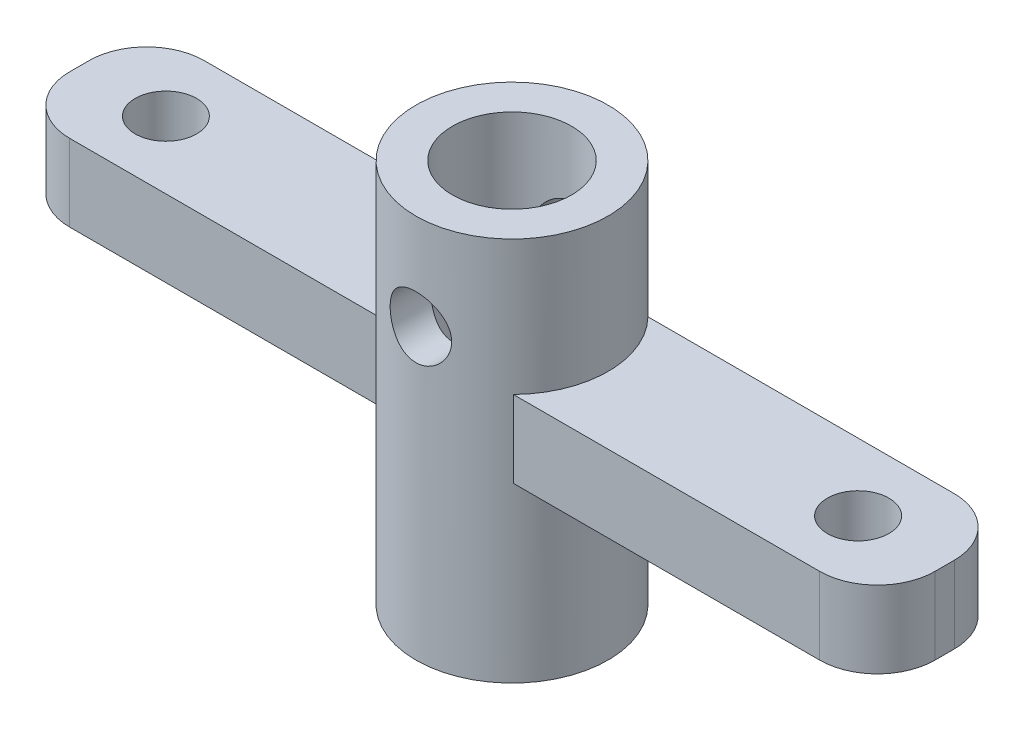
from build123d import *

# Parameters (mm, degrees)
SKETCH_1_R               = 5
SKETCH_1_R_2             = 3.1
EXTRUDE_1_DEPTH          = 20
SKETCH_2_W               = 45
SKETCH_2_H               = 4
EXTRUDE_2_DEPTH          = 3.5
SKETCH_4_R               = 1.6
CUT_EXTRUDE_2_DEPTH      = 14
FILLET_1_R               = 3
SKETCH_5_R               = 1.6
CUT_EXTRUDE_3_DEPTH      = 6
CUT_EXTRUDE_3_DEPTH_BACK = 6
SKETCH_3_R               = 3.1
CUT_EXTRUDE_4_DEPTH      = 8.0000001
CUT_EXTRUDE_4_DEPTH_BACK = 14.0000001


with BuildPart() as part:
    # 草图1 → 凸台-拉伸1 (new body)
    with BuildSketch(Plane(origin=(0, 0, 0), x_dir=(1, 0, 0), z_dir=(0, 1, 0))):
        Circle(SKETCH_1_R)
        Circle(SKETCH_1_R_2, mode=Mode.SUBTRACT)
    extrude(amount=EXTRUDE_1_DEPTH)

    # 草图2 → 凸台-拉伸2 (add, symmetric)
    with BuildSketch(Plane.XY):
        with Locations((0, 11)):
            Rectangle(SKETCH_2_W, SKETCH_2_H)
    extrude(amount=EXTRUDE_2_DEPTH, both=True)

    # 草图4 → 切除-拉伸2 (cut, through all)
    with BuildSketch(Plane(origin=(0, 13, 0), x_dir=(1, 0, 0), z_dir=(0, 1, 0))):
        with Locations((-18, 0)):
            Circle(SKETCH_4_R)
        with Locations((18, 0)):
            Circle(SKETCH_4_R)
    extrude(amount=-CUT_EXTRUDE_2_DEPTH, mode=Mode.SUBTRACT)

    # 圆角1
    fillet_1_edges = [part.edges().sort_by_distance(p)[0] for p in [
        (22.5, 11, 3.5),
        (-22.5, 11, 3.5),
        (-22.5, 11, -3.5),
        (22.5, 11, -3.5),
    ]]
    fillet(fillet_1_edges, radius=FILLET_1_R)

    # 草图5 → 切除-拉伸3 (cut, two sides)
    with BuildSketch(Plane.XY) as cut_extrude_3_sk:
        with Locations((0, 15)):
            Circle(SKETCH_5_R)
    extrude(amount=CUT_EXTRUDE_3_DEPTH, mode=Mode.SUBTRACT)
    extrude(cut_extrude_3_sk.sketch, amount=-CUT_EXTRUDE_3_DEPTH_BACK, mode=Mode.SUBTRACT)

    # 草图3 → 切除-拉伸4 (cut, two sides)
    with BuildSketch(Plane(origin=(0, 13, 0), x_dir=(1, 0, 0), z_dir=(0, 1, 0))) as cut_extrude_4_sk:
        Circle(SKETCH_3_R)
    extrude(amount=CUT_EXTRUDE_4_DEPTH, mode=Mode.SUBTRACT)
    extrude(cut_extrude_4_sk.sketch, amount=-CUT_EXTRUDE_4_DEPTH_BACK, mode=Mode.SUBTRACT)


solid = part.part
